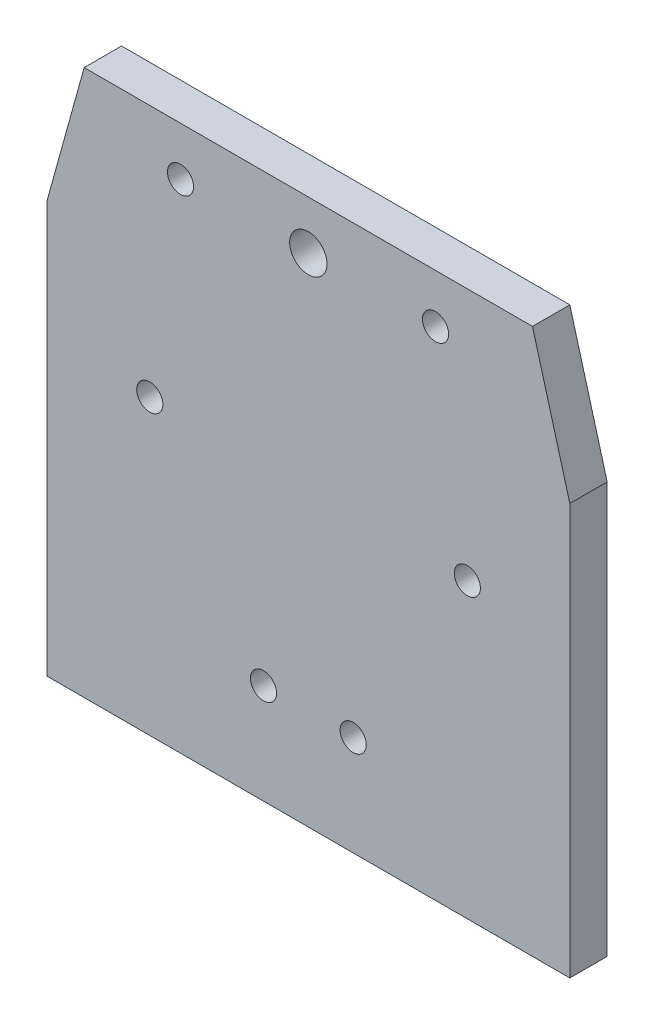
from build123d import *

# Parameters (mm, degrees)
SKETCH1_R           = 1.75
SKETCH1_R_2         = 2.5
BOSS_EXTRUDE1_DEPTH = 5


with BuildPart() as part:
    # Sketch1 → Boss-Extrude1 (new body)
    with BuildSketch(Plane.XY):
        Polygon((434.94254699, 291.200534556), (434.94254699, 236.200534556), (364.94254699, 236.200534556), (364.94254699, 291.200534556), (369.94254699, 309.228290933), (429.94254699, 309.228290933), align=None)
        with Locations((421.224628764, 275.399946991)):
            Circle(SKETCH1_R, mode=Mode.SUBTRACT)
        with Locations((378.724642278, 275.433838704)):
            Circle(SKETCH1_R, mode=Mode.SUBTRACT)
        with Locations((393.945927789, 249.582098582)):
            Circle(SKETCH1_R, mode=Mode.SUBTRACT)
        with Locations((405.945927789, 249.582098582)):
            Circle(SKETCH1_R, mode=Mode.SUBTRACT)
        with Locations((382.83616052, 302.717706753)):
            Circle(SKETCH1_R, mode=Mode.SUBTRACT)
        with Locations((416.968403726, 302.717706753)):
            Circle(SKETCH1_R, mode=Mode.SUBTRACT)
        with Locations((399.94254699, 302.717706753)):
            Circle(SKETCH1_R_2, mode=Mode.SUBTRACT)
    extrude(amount=BOSS_EXTRUDE1_DEPTH)


solid = part.part
